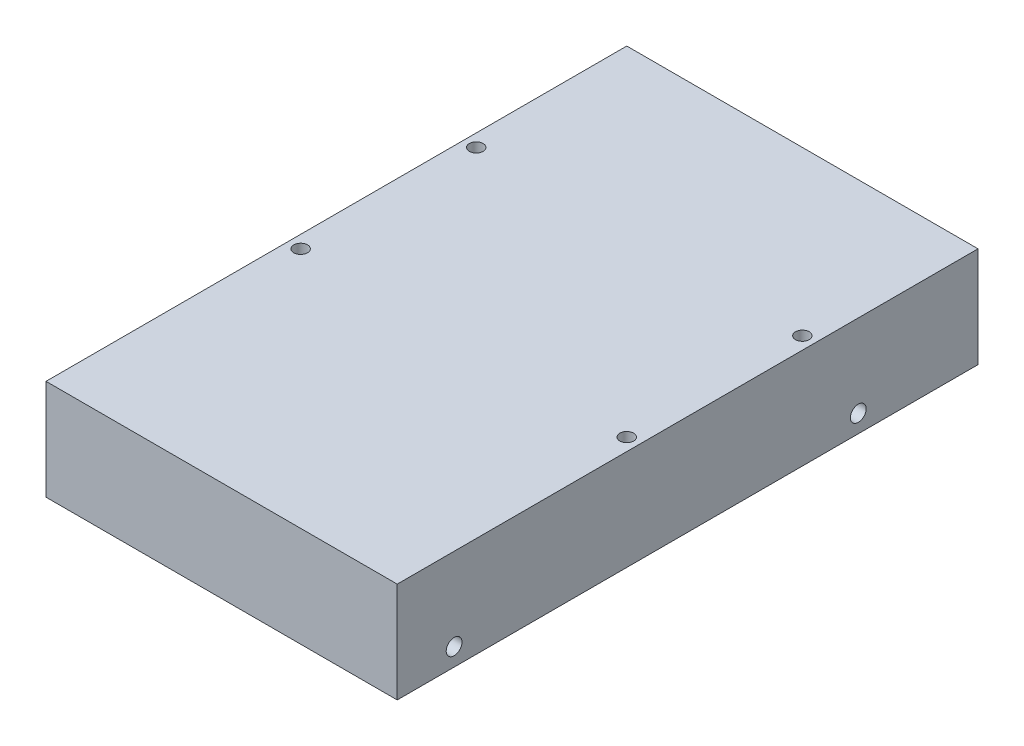
from build123d import *

# Parameters (mm, degrees)
SKETCH1_W           = 88.9
SKETCH1_H           = 147
BOSS_EXTRUDE1_DEPTH = 25.4
SKETCH2_R           = 1.74244
CUT_EXTRUDE1_DEPTH  = 30
CUT_EXTRUDE2_REACH  = 90.9
SKETCH3_R           = 2


with BuildPart() as part:
    # Sketch1 → Boss-Extrude1 (new body)
    with BuildSketch(Plane(origin=(0, 0, 0), x_dir=(1, 0, 0), z_dir=(0, 1, 0))):
        Rectangle(SKETCH1_W, SKETCH1_H)
    extrude(amount=BOSS_EXTRUDE1_DEPTH)

    # Sketch2 → Cut-Extrude1 (cut)
    with BuildSketch(Plane.XZ):
        with Locations((41.27, -32.22)):
            Circle(SKETCH2_R)
        with Locations((41.27, 12.23)):
            Circle(SKETCH2_R)
        with Locations((-41.27, -32.22)):
            Circle(SKETCH2_R)
        with Locations((-41.27, 12.23)):
            Circle(SKETCH2_R)
    extrude(amount=-CUT_EXTRUDE1_DEPTH, mode=Mode.SUBTRACT)

    # Sketch3 → Cut-Extrude2 (cut, up to next)
    with BuildSketch(Plane(origin=(44.45, 0, 0), x_dir=(0, 0, -1), z_dir=(1, 0, 0)), mode=Mode.PRIVATE) as cut_extrude2_sk1:
        with Locations((-59.1, 4.5)):
            Circle(SKETCH3_R)
    cut_extrude2_tool1 = extrude(cut_extrude2_sk1.sketch, amount=-CUT_EXTRUDE2_REACH, mode=Mode.PRIVATE) & part.part
    add(cut_extrude2_tool1.solids().sort_by_distance((44.45, 4.5, 59.1))[0], mode=Mode.SUBTRACT)
    # Sketch3 → Cut-Extrude2 (cut, up to next)
    with BuildSketch(Plane(origin=(44.45, 0, 0), x_dir=(0, 0, -1), z_dir=(1, 0, 0)), mode=Mode.PRIVATE) as cut_extrude2_sk2:
        with Locations((43.2, 4.5)):
            Circle(SKETCH3_R)
    cut_extrude2_tool2 = extrude(cut_extrude2_sk2.sketch, amount=-CUT_EXTRUDE2_REACH, mode=Mode.PRIVATE) & part.part
    add(cut_extrude2_tool2.solids().sort_by_distance((44.45, 4.5, -43.2))[0], mode=Mode.SUBTRACT)


solid = part.part
